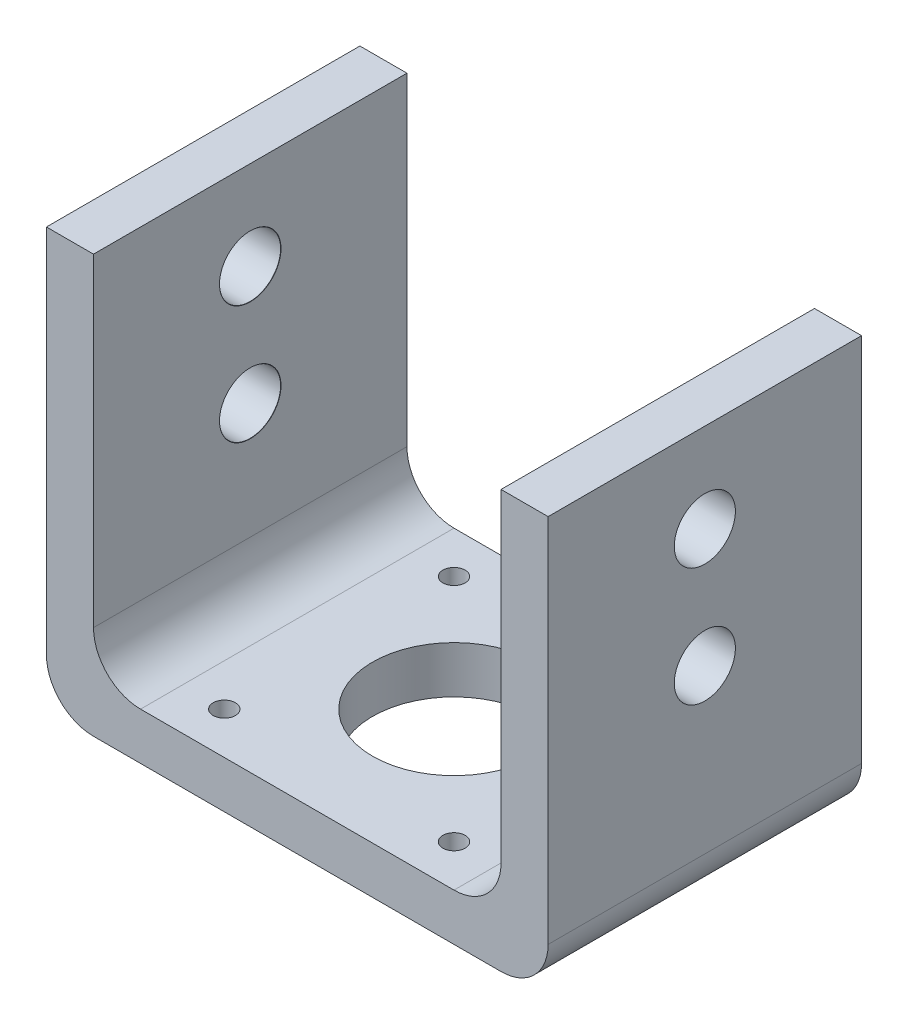
from build123d import *

# Parameters (mm, degrees)
SKETCH1_W                              = 42.3
SKETCH1_H                              = 42.3
BOSS_EXTRUDE1_DEPTH                    = 6.35
SKETCH2_R                              = 11
SKETCH2_R_2                            = 1.5
CUT_EXTRUDE1_DEPTH                     = 6.35
SKETCH3_W                              = 42.3
SKETCH3_H                              = 6.35
BOSS_EXTRUDE2_DEPTH                    = 12.7
SKETCH4_W                              = 6.35
SKETCH4_H                              = 42.3
BOSS_EXTRUDE3_DEPTH                    = 50
FILLET1_R                              = 6.35
FILLET2_R                              = 6.35
TAP_DRILL_FOR_M8_HELICOIL1_D           = 8.25
TAP_DRILL_FOR_M8_HELICOIL1_DEPTH       = 6.35
TAP_DRILL_FOR_M8_HELICOIL1_CSINK_D     = 8.3
TAP_DRILL_FOR_M8_HELICOIL1_CSINK_ANGLE = 90
FILLET1_OF_MIRROR4_R                   = 6.35
FILLET2_OF_MIRROR4_R                   = 6.35


with BuildPart() as part:
    # Sketch1 → Boss-Extrude1 (new body)
    with BuildSketch(Plane(origin=(0, 0, 0), x_dir=(1, 0, 0), z_dir=(0, 1, 0))):
        with Locations((21.15, -21.15)):
            Rectangle(SKETCH1_W, SKETCH1_H)
    extrude(amount=BOSS_EXTRUDE1_DEPTH)

    # Sketch2 → Cut-Extrude1 (cut)
    with BuildSketch(Plane(origin=(0, 6.35, 0), x_dir=(1, 0, 0), z_dir=(0, 1, 0))):
        with Locations(Location((21.15, -21.15, 0), (0, 0, 270))):
            Circle(SKETCH2_R)
        with Locations(Location((5.65, -5.65, 0), (0, 0, 270))):
            Circle(SKETCH2_R_2)
        with Locations(Location((5.65, -36.65, 0), (0, 0, 270))):
            Circle(SKETCH2_R_2)
        with Locations(Location((36.65, -5.65, 0), (0, 0, 270))):
            Circle(SKETCH2_R_2)
        with Locations(Location((36.65, -36.65, 0), (0, 0, 270))):
            Circle(SKETCH2_R_2)
    extrude(amount=-CUT_EXTRUDE1_DEPTH, mode=Mode.SUBTRACT)

    # Sketch3 → Boss-Extrude2 (add)
    with BuildSketch(Plane(origin=(42.3, 0, 0), x_dir=(0, 0, -1), z_dir=(1, 0, 0))):
        with Locations((-21.15, 3.175)):
            Rectangle(SKETCH3_W, SKETCH3_H)
    boss_extrude2 = extrude(amount=BOSS_EXTRUDE2_DEPTH)

    # Sketch4 → Boss-Extrude3 (add)
    with BuildSketch(Plane(origin=(0, 6.35, 0), x_dir=(1, 0, 0), z_dir=(0, 1, 0))):
        with Locations((51.825, -21.15)):
            Rectangle(SKETCH4_W, SKETCH4_H)
    boss_extrude3 = extrude(amount=BOSS_EXTRUDE3_DEPTH)

    # Fillet1
    fillet1_edges = [part.edges().sort_by_distance(p)[0] for p in [
        (48.65, 6.35, 21.15),
    ]]
    fillet(fillet1_edges, radius=FILLET1_R)

    # Fillet2
    fillet2_edges = [part.edges().sort_by_distance(p)[0] for p in [
        (55, 0, 21.15),
    ]]
    fillet(fillet2_edges, radius=FILLET2_R)

    # Tap Drill for M8 Helicoil1
    with Locations(Plane.ZY.offset(-48.65)):
        with Locations((21.15, 44.35), (21.15, 28.35)):
            tap_drill_for_m8_helicoil1 = CounterSinkHole(TAP_DRILL_FOR_M8_HELICOIL1_D / 2, TAP_DRILL_FOR_M8_HELICOIL1_CSINK_D / 2, depth=TAP_DRILL_FOR_M8_HELICOIL1_DEPTH, counter_sink_angle=TAP_DRILL_FOR_M8_HELICOIL1_CSINK_ANGLE)

    # Mirror4: Boss-Extrude2, Boss-Extrude3, Tap Drill for M8 Helicoil1 across plane
    add(boss_extrude2.mirror(Plane.ZY.offset(-21.15)))
    add(boss_extrude3.mirror(Plane.ZY.offset(-21.15)))
    add(tap_drill_for_m8_helicoil1.mirror(Plane.ZY.offset(-21.15)), mode=Mode.SUBTRACT)

    # Fillet1 of Mirror4
    fillet1_of_mirror4_edges = [part.edges().sort_by_distance(p)[0] for p in [
        (-6.35, 6.35, 21.15),
    ]]
    fillet(fillet1_of_mirror4_edges, radius=FILLET1_OF_MIRROR4_R)

    # Fillet2 of Mirror4
    fillet2_of_mirror4_edges = [part.edges().sort_by_distance(p)[0] for p in [
        (-12.7, 0, 21.15),
    ]]
    fillet(fillet2_of_mirror4_edges, radius=FILLET2_OF_MIRROR4_R)


solid = part.part
